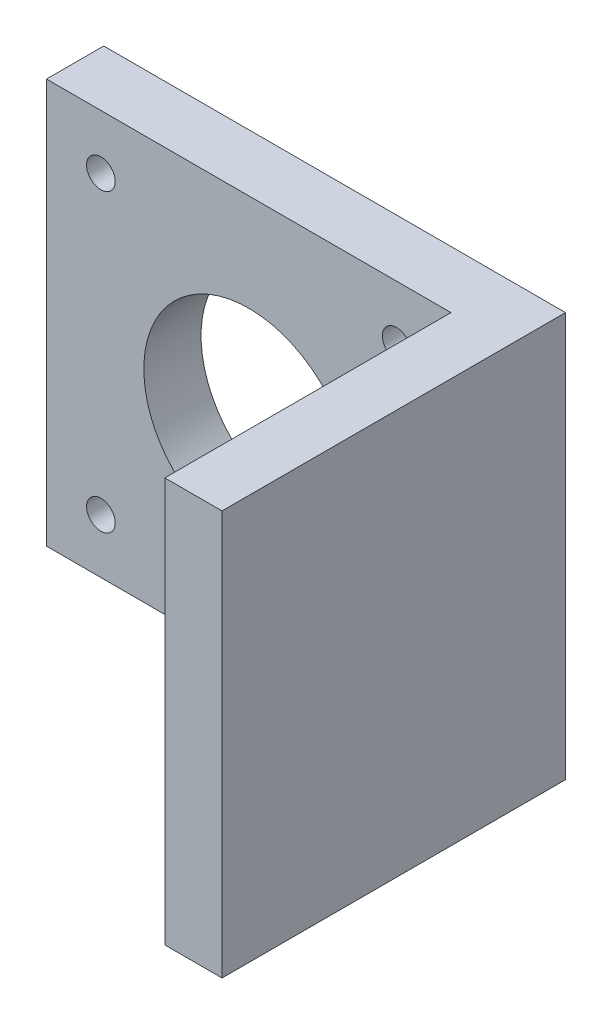
from build123d import *

# Parameters (mm, degrees)
BOSS_EXTRUDE1_DEPTH = 42.4
SKETCH3_R           = 11
SKETCH3_R_2         = 1.5
CUT_EXTRUDE1_DEPTH  = 7


with BuildPart() as part:
    # Sketch2 → Boss-Extrude1 (new body)
    with BuildSketch(Plane(origin=(0, 0, 0), x_dir=(1, 0, 0), z_dir=(0, 1, 0))):
        Polygon((-42.4, 0), (0, 0), (0, -30), (6, -30), (6, 6), (-42.4, 6), align=None)
    extrude(amount=BOSS_EXTRUDE1_DEPTH)

    # Sketch3 → Cut-Extrude1 (cut, through all)
    with BuildSketch(Plane.XY):
        with Locations((-21.2, 21.2)):
            Circle(SKETCH3_R)
        with Locations((-36.7, 36.7)):
            Circle(SKETCH3_R_2)
        with Locations((-5.7, 36.7)):
            Circle(SKETCH3_R_2)
        with Locations((-5.7, 5.7)):
            Circle(SKETCH3_R_2)
        with Locations((-36.7, 5.7)):
            Circle(SKETCH3_R_2)
    extrude(amount=-CUT_EXTRUDE1_DEPTH, mode=Mode.SUBTRACT)


solid = part.part
